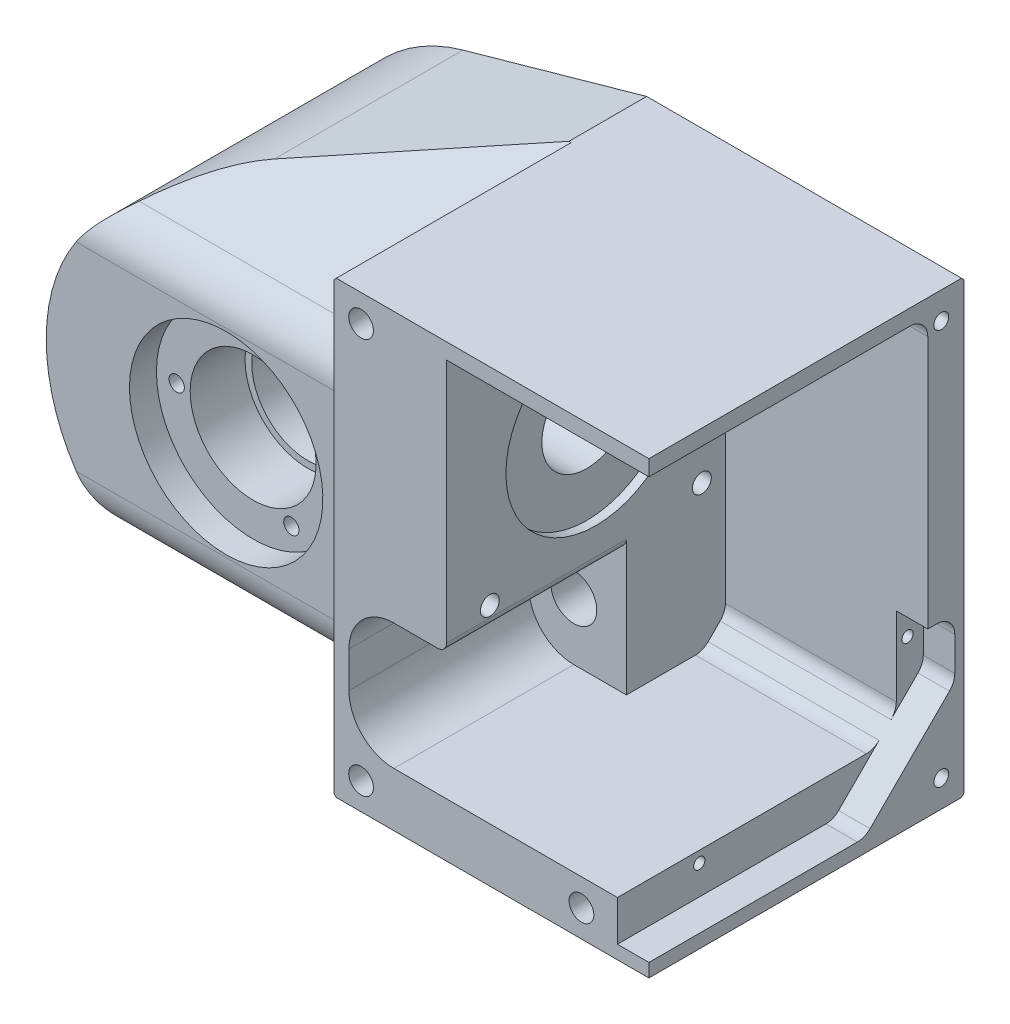
from build123d import *

# Parameters (mm, degrees)
ESQUISSE1_R                                        = 6.328378155
BOSS_EXTRU_1_DEPTH                                 = 70
ENL_V_MAT_EXTRU_3_DEPTH                            = 45
CONG_3_R                                           = 4
ESQUISSE5_R                                        = 20
ENL_V_MAT_EXTRU_4_DEPTH                            = 2
ESQUISSE6_R                                        = 10
ENL_V_MAT_EXTRU_5_DEPTH                            = 65
TROU_POUR_TARAUDAGE_POUR_TROU_TARAUD_M5_D          = 4.2
TROU_POUR_TARAUDAGE_POUR_TROU_TARAUD_M5_DEPTH      = 8
TROU_POUR_TARAUDAGE_POUR_TROU_TARAUD_M5_TIP        = 1.2618073
ENL_V_MAT_EXTRU_6_DEPTH                            = 45
CONG_5_R                                           = 4
ENL_V_MAT_EXTRU_7_DEPTH                            = 132.909059583
ENL_V_MAT_EXTRU_10_DEPTH                           = 30
ENL_V_MAT_EXTRU_10_DEPTH_BACK                      = 132.909059583
CHAMBRAGE_POUR_VIS_T_TE_HEXAGONALE_M51_D           = 5.5
CHAMBRAGE_POUR_VIS_T_TE_HEXAGONALE_M51_DEPTH       = 90
CHAMBRAGE_POUR_VIS_T_TE_HEXAGONALE_M51_CBORE_D     = 10
CHAMBRAGE_POUR_VIS_T_TE_HEXAGONALE_M51_CBORE_DEPTH = 40
CHAMBRAGE_POUR_VIS_T_TE_HEXAGONALE_M51_TIP         = 1.652366702
TROU_POUR_TARAUDAGE_POUR_TROU_TARAUD_M1_D          = 10.2
TROU_POUR_TARAUDAGE_POUR_TROU_TARAUD_M1_DEPTH      = 30
TROU_POUR_TARAUDAGE_POUR_TROU_TARAUD_M1_TIP        = 3.064389157
ESQUISSE20_R                                       = 6.5
ENL_V_MAT_EXTRU_11_DEPTH                           = 10
ENL_V_START                                        = -30
ENL_V_MAT_EXTRU_13_DEPTH                           = 45
CONG_9_R                                           = 2
TROU_POUR_TARAUDAGE_POUR_TROU_TARAUD_M4_D          = 3.3
TROU_POUR_TARAUDAGE_POUR_TROU_TARAUD_M4_DEPTH      = 8
TROU_POUR_TARAUDAGE_POUR_TROU_TARAUD_M4_TIP        = 0.991420021
CHANFREIN1_SIZE                                    = 0.5
D_GAGEMENT_M31_D                                   = 3.4
D_GAGEMENT_M31_DEPTH                               = 8
D_GAGEMENT_M31_TIP                                 = 1.021463052
ENL_V_MAT_EXTRU_25_DEPTH                           = 7
CONG_10_R                                          = 4
TROU_POUR_TARAUDAGE_POUR_TROU_TARAUD_M3_D          = 2.5
TROU_POUR_TARAUDAGE_POUR_TROU_TARAUD_M3_DEPTH      = 6
TROU_POUR_TARAUDAGE_POUR_TROU_TARAUD_M3_TIP        = 0.751075774


with BuildPart() as part:
    # Esquisse1 → Boss.-Extru.1 (new body)
    with BuildSketch(Plane.XY):
        Polygon((100, -50), (100, 50), (30, 50), (-40, 50), (-40, -50), (30, -50), align=None)
        Circle(ESQUISSE1_R, mode=Mode.SUBTRACT)
    extrude(amount=BOSS_EXTRU_1_DEPTH)

    # Esquisse9 → Enlèvement de matière-Révolution1 (revolve, cut)
    with BuildSketch(Plane(origin=(0, 0, 0), x_dir=(1, 0, 0), z_dir=(0, 1, 0))):
        Polygon((0, 0), (0, -70), (21.5, -70), (21.5, -58), (14, -58), (14, -45.8), (12.5, -45.8), (12.5, -18), (21, -18), (21, -6), (38, -6), (38, 0), align=None)
    revolve(axis=Axis((0, 0, 0), (0, 0, 1)), mode=Mode.SUBTRACT)

    # Esquisse4 → Enlèv. mat.-Extru.3 (cut)
    with BuildSketch(Plane(origin=(100, 0, 0), x_dir=(0, 0, -1), z_dir=(1, 0, 0))):
        Polygon((-65, -10.5), (-8, -10.5), (-8, 46.5), (-65, 46.5), (-70, 46.5), (-70, -10.5), align=None)
    extrude(amount=-ENL_V_MAT_EXTRU_3_DEPTH, mode=Mode.SUBTRACT)

    # Congé3
    cong_3_edges = [part.edges().sort_by_distance(p)[0] for p in [
        (77.5, -10.5, 8),
        (77.5, 46.5, 8),
    ]]
    fillet(cong_3_edges, radius=CONG_3_R)

    # Esquisse5 → Enlèv. mat.-Extru.4 (cut)
    with BuildSketch(Plane(origin=(55, 0, 0), x_dir=(0, 0, -1), z_dir=(1, 0, 0))):
        with Locations((-36.8, 18)):
            Circle(ESQUISSE5_R)
    extrude(amount=-ENL_V_MAT_EXTRU_4_DEPTH, mode=Mode.SUBTRACT)

    # Esquisse6 → Enlèv. mat.-Extru.5 (cut)
    with BuildSketch(Plane(origin=(53, 0, 0), x_dir=(0, 0, -1), z_dir=(1, 0, 0))):
        with Locations((-36.8, 18)):
            Circle(ESQUISSE6_R)
    extrude(amount=-ENL_V_MAT_EXTRU_5_DEPTH, mode=Mode.SUBTRACT)

    # Trou pour taraudage pour trou taraudé M51
    with Locations(Plane(origin=(55, 0, 0), x_dir=(0, 0, -1), z_dir=(1, 0, 0))):
        with Locations((-36.8, 18), (-13.23, 41.57), (-60.37, -5.57), (-60.37, 41.57), (-13.23, -5.57)):
            Hole(TROU_POUR_TARAUDAGE_POUR_TROU_TARAUD_M5_D / 2, depth=TROU_POUR_TARAUDAGE_POUR_TROU_TARAUD_M5_DEPTH)
            with Locations((0, 0, -(TROU_POUR_TARAUDAGE_POUR_TROU_TARAUD_M5_DEPTH + TROU_POUR_TARAUDAGE_POUR_TROU_TARAUD_M5_TIP / 2))):  # 118° drill point
                Cone(0, TROU_POUR_TARAUDAGE_POUR_TROU_TARAUD_M5_D / 2, TROU_POUR_TARAUDAGE_POUR_TROU_TARAUD_M5_TIP, mode=Mode.SUBTRACT)

    # Esquisse10 → Enlèv. mat.-Extru.6 (cut)
    with BuildSketch(Plane(origin=(100, 0, 0), x_dir=(0, 0, -1), z_dir=(1, 0, 0))):
        Polygon((-13, -38), (-70, -38), (-70, -2.141745164), (-8, -2.141745164), (-8, -33), align=None)
    extrude(amount=-ENL_V_MAT_EXTRU_6_DEPTH, mode=Mode.SUBTRACT)

    # Congé5
    cong_5_edges = [part.edges().sort_by_distance(p)[0] for p in [
        (77.5, -33, 8),
        (77.5, -38, 13),
    ]]
    fillet(cong_5_edges, radius=CONG_5_R)

    # Esquisse11 → Enlèv. mat.-Extru.7 (cut, through all)
    with BuildSketch(Plane(origin=(0, 0, 0), x_dir=(-1, 0, 0), z_dir=(0, 0, -1))):
        with BuildLine():
            Line((40, 50), (-30, 50))
            Line((-30, 50), (10.839062865, 38.503437719))
            ThreePointArc((10.839062865, 38.503437719), (31.887007689, 24.149922166), (40, -1.07e-07))
            Line((40, -1.07e-07), (40, 50))
        make_face()
        with BuildLine():
            Line((40, -50), (40, -1.07e-07))
            ThreePointArc((40, -1.07e-07), (31.887007625, -24.149922251), (10.839062865, -38.503437719))
            Line((10.839062865, -38.503437719), (-30, -50))
            Line((-30, -50), (40, -50))
        make_face()
    extrude(amount=-ENL_V_MAT_EXTRU_7_DEPTH, mode=Mode.SUBTRACT)

    # Esquisse14 → Enlèv. mat.-Extru.10 (cut, two sides: drawn at the far end of the back side and taken through both)
    with BuildSketch(Plane(origin=(0, 0, 0), x_dir=(0, 0, -1), z_dir=(1, 0, 0)).offset(-ENL_V_MAT_EXTRU_10_DEPTH_BACK)):
        with BuildLine():
            Line((-17.774653975, 50), (-58.226182617, 31.13714241))
            ThreePointArc((-58.226182617, 31.13714241), (-62.433914458, 27.447060623), (-64, 22.074064539))
            Line((-64, 22.074064539), (-64, -22.074064539))
            ThreePointArc((-64, -22.074064539), (-62.433914458, -27.447060623), (-58.226182617, -31.13714241))
            Line((-58.226182617, -31.13714241), (-17.774653975, -50))
            Line((-17.774653975, -50), (-70, -50))
            Line((-70, -50), (-70, 50))
            Line((-70, 50), (-17.774653975, 50))
        make_face()
    extrude(amount=ENL_V_MAT_EXTRU_10_DEPTH + ENL_V_MAT_EXTRU_10_DEPTH_BACK, mode=Mode.SUBTRACT)

    # Chambrage pour vis à tête hexagonale M51
    with Locations(Plane(origin=(0, 0, 0), x_dir=(-1, 0, 0), z_dir=(0, 0, -1))):
        with Locations((-85, -44), (-36, -44), (-36, 44)):
            CounterBoreHole(CHAMBRAGE_POUR_VIS_T_TE_HEXAGONALE_M51_D / 2, CHAMBRAGE_POUR_VIS_T_TE_HEXAGONALE_M51_CBORE_D / 2, CHAMBRAGE_POUR_VIS_T_TE_HEXAGONALE_M51_CBORE_DEPTH, depth=CHAMBRAGE_POUR_VIS_T_TE_HEXAGONALE_M51_DEPTH)
            with Locations((0, 0, -(CHAMBRAGE_POUR_VIS_T_TE_HEXAGONALE_M51_DEPTH + CHAMBRAGE_POUR_VIS_T_TE_HEXAGONALE_M51_TIP / 2))):  # 118° drill point
                Cone(0, CHAMBRAGE_POUR_VIS_T_TE_HEXAGONALE_M51_D / 2, CHAMBRAGE_POUR_VIS_T_TE_HEXAGONALE_M51_TIP, mode=Mode.SUBTRACT)

    # Trou pour taraudage pour trou taraudé M121
    with Locations(Plane(origin=(0, 0, 0), x_dir=(-1, 0, 0), z_dir=(0, 0, -1))):
        with Locations((-43.301270189, -25)):
            Hole(TROU_POUR_TARAUDAGE_POUR_TROU_TARAUD_M1_D / 2, depth=TROU_POUR_TARAUDAGE_POUR_TROU_TARAUD_M1_DEPTH)
            with Locations((0, 0, -(TROU_POUR_TARAUDAGE_POUR_TROU_TARAUD_M1_DEPTH + TROU_POUR_TARAUDAGE_POUR_TROU_TARAUD_M1_TIP / 2))):  # 118° drill point
                Cone(0, TROU_POUR_TARAUDAGE_POUR_TROU_TARAUD_M1_D / 2, TROU_POUR_TARAUDAGE_POUR_TROU_TARAUD_M1_TIP, mode=Mode.SUBTRACT)

    # Esquisse20 → Enlèv. mat.-Extru.11 (cut)
    with BuildSketch(Plane(origin=(0, 0, 0), x_dir=(-1, 0, 0), z_dir=(0, 0, -1))):
        with Locations((-43.301270189, -25)):
            Circle(ESQUISSE20_R)
    extrude(amount=-ENL_V_MAT_EXTRU_11_DEPTH, mode=Mode.SUBTRACT)

    # Esquisse24 → Enlèv. mat.-Extru.13 (cut)
    with BuildSketch(Plane(origin=(0, 0, 0), x_dir=(-1, 0, 0), z_dir=(0, 0, -1)).offset(ENL_V_START)):
        with BuildLine():
            Line((-43.301270189, -10), (-55, -10))
            Line((-55, -10), (-55, -38))
            Line((-55, -38), (-43.301270189, -38))
            ThreePointArc((-43.301270189, -38), (-36.230202377, -35.071067812), (-33.301270189, -28))
            Line((-33.301270189, -28), (-33.301270189, -20))
            ThreePointArc((-33.301270189, -20), (-36.230202377, -12.928932188), (-43.301270189, -10))
        make_face()
    extrude(amount=-ENL_V_MAT_EXTRU_13_DEPTH, mode=Mode.SUBTRACT)

    # Congé9
    cong_9_edges = [part.edges().sort_by_distance(p)[0] for p in [
        (55, -10, 50),
    ]]
    fillet(cong_9_edges, radius=CONG_9_R)

    # Trou pour taraudage pour trou taraudé M41
    with Locations(Plane(origin=(100, 0, 0), x_dir=(0, 0, -1), z_dir=(1, 0, 0))):
        with Locations((-5, -44), (-5, 44)):
            Hole(TROU_POUR_TARAUDAGE_POUR_TROU_TARAUD_M4_D / 2, depth=TROU_POUR_TARAUDAGE_POUR_TROU_TARAUD_M4_DEPTH)
            with Locations((0, 0, -(TROU_POUR_TARAUDAGE_POUR_TROU_TARAUD_M4_DEPTH + TROU_POUR_TARAUDAGE_POUR_TROU_TARAUD_M4_TIP / 2))):  # 118° drill point
                Cone(0, TROU_POUR_TARAUDAGE_POUR_TROU_TARAUD_M4_D / 2, TROU_POUR_TARAUDAGE_POUR_TROU_TARAUD_M4_TIP, mode=Mode.SUBTRACT)

    # Chanfrein1
    chanfrein1_edges = [part.edges().sort_by_distance(p)[0] for p in [
        (9.580468567, 44.25171886, 0),
        (-40, 0, 0),
        (9.580468567, -44.25171886, 0),
        (65, -50, 0),
        (65, 50, 0),
        (-12.5, 0, 18),
        (-21, 0, 6),
        (-38, 0, 0),
        (30, -50, 43.887326987),
        (30, 50, 43.887326987),
    ]]
    chamfer(chanfrein1_edges, length=CHANFREIN1_SIZE)

    # Dégagement M31
    with Locations(Plane.XY.offset(58)):
        with Locations((-17, 0), (8.5, 14.722431864), (8.5, -14.722431864), (0, 0)):
            Hole(D_GAGEMENT_M31_D / 2, depth=D_GAGEMENT_M31_DEPTH)
            with Locations((0, 0, -(D_GAGEMENT_M31_DEPTH + D_GAGEMENT_M31_TIP / 2))):  # 118° drill point
                Cone(0, D_GAGEMENT_M31_D / 2, D_GAGEMENT_M31_TIP, mode=Mode.SUBTRACT)

    # Esquisse32 → Enlèv. mat.-Extru.25 (cut)
    with BuildSketch(Plane(origin=(100, 0, 0), x_dir=(0, 0, -1), z_dir=(1, 0, 0))):
        Polygon((-70, -47), (-22, -47), (-2, -27), (-2, -13.8), (-70, -13.8), align=None)
    extrude(amount=-ENL_V_MAT_EXTRU_25_DEPTH, mode=Mode.SUBTRACT)

    # Congé10
    cong_10_edges = [part.edges().sort_by_distance(p)[0] for p in [
        (96.5, -13.8, 2),
        (96.5, -27, 2),
        (96.5, -47, 22),
    ]]
    fillet(cong_10_edges, radius=CONG_10_R)

    # Trou pour taraudage pour trou taraudé M31
    with Locations(Plane(origin=(93, 0, 0), x_dir=(0, 0, -1), z_dir=(1, 0, 0))):
        with Locations((-5.5, -20), (-51.8, -40.5)):
            Hole(TROU_POUR_TARAUDAGE_POUR_TROU_TARAUD_M3_D / 2, depth=TROU_POUR_TARAUDAGE_POUR_TROU_TARAUD_M3_DEPTH)
            with Locations((0, 0, -(TROU_POUR_TARAUDAGE_POUR_TROU_TARAUD_M3_DEPTH + TROU_POUR_TARAUDAGE_POUR_TROU_TARAUD_M3_TIP / 2))):  # 118° drill point
                Cone(0, TROU_POUR_TARAUDAGE_POUR_TROU_TARAUD_M3_D / 2, TROU_POUR_TARAUDAGE_POUR_TROU_TARAUD_M3_TIP, mode=Mode.SUBTRACT)


solid = part.part
